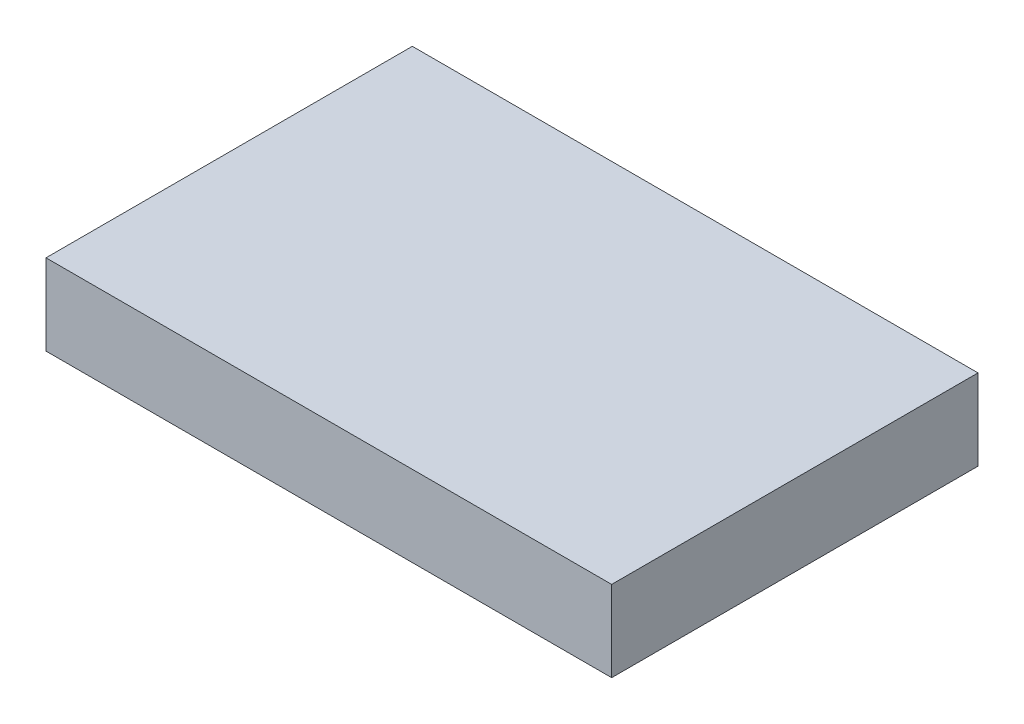
from build123d import *

# Parameters (mm, degrees)
SKETCH1_W           = 21
SKETCH1_H           = 13.6
BOSS_EXTRUDE1_DEPTH = 3


with BuildPart() as part:
    # Sketch1 → Boss-Extrude1 (new body)
    with BuildSketch(Plane(origin=(0, 0, 0), x_dir=(1, 0, 0), z_dir=(0, 1, 0))):
        with Locations((10.5, -6.8)):
            Rectangle(SKETCH1_W, SKETCH1_H)
    extrude(amount=BOSS_EXTRUDE1_DEPTH)


solid = part.part
